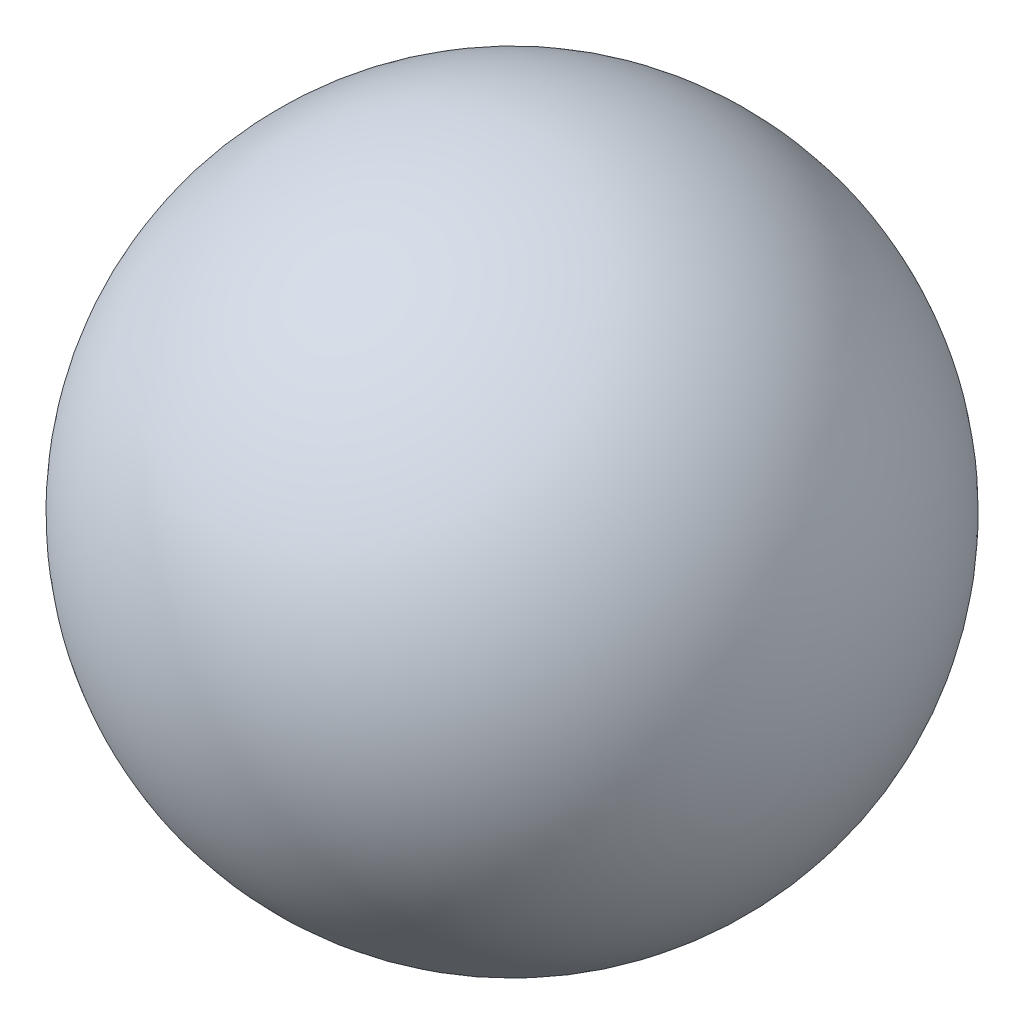
from build123d import *


with BuildPart() as part:
    # Sketch2 → Revolve1 (revolve)
    with BuildSketch(Plane.YZ):
        with BuildLine():
            Line((0, -9.525), (0, 9.525))
            ThreePointArc((0, 9.525), (9.525, 0), (0, -9.525))
        make_face()
    revolve(axis=Axis((0, 0, -9.525), (0, 0, 1)))


solid = part.part
